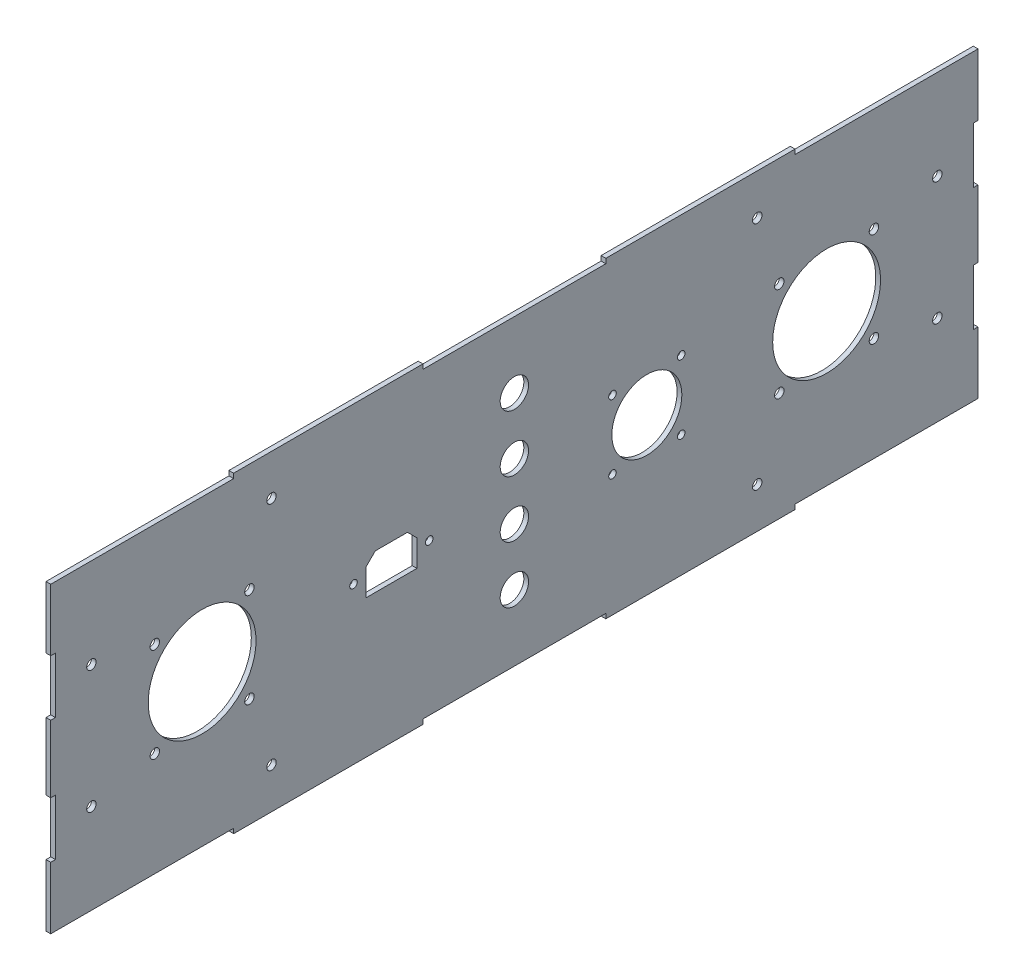
from build123d import *

# Parameters (mm, degrees)
BOSS_EXTRUDE1_DEPTH = 2.5
SKETCH2_R           = 2.5
SKETCH2_R_2         = 2
SKETCH2_R_3         = 18.5
SKETCH2_R_4         = 28.5
SKETCH2_R_5         = 7.5
SKETCH2_W           = 2.5
SKETCH2_H           = 29.5
CUT_EXTRUDE1_DEPTH  = 2.5


with BuildPart() as part:
    # Sketch1 → Boss-Extrude1 (new body)
    with BuildSketch(Plane(origin=(0, 0, 0), x_dir=(0, 0, -1), z_dir=(1, 0, 0))):
        Polygon((-245, -80), (-148.333333333, -80), (-148.333333333, -82.5), (-48.333333333, -82.5), (-48.333333333, -80), (48.333333333, -80), (48.333333333, -82.5), (148.333333333, -82.5), (148.333333333, -80), (245, -80), (245, 80), (148.333333333, 80), (148.333333333, 82.5), (48.333333333, 82.5), (48.333333333, 80), (-48.333333333, 80), (-48.333333333, 82.5), (-148.333333333, 82.5), (-148.333333333, 80), (-245, 80), align=None)
    extrude(amount=BOSS_EXTRUDE1_DEPTH)

    # Sketch2 → Cut-Extrude1 (cut)
    with BuildSketch(Plane(origin=(2.5, 0, 0), x_dir=(0, 0, -1), z_dir=(1, 0, 0))):
        with Locations((-128.333333333, 61)):
            Circle(SKETCH2_R)
        with Locations((128.333333333, 61)):
            Circle(SKETCH2_R)
        with Locations((128.333333333, -61)):
            Circle(SKETCH2_R)
        with Locations((-128.333333333, -61)):
            Circle(SKETCH2_R)
        with Locations((-223.5, 32.5)):
            Circle(SKETCH2_R)
        with Locations((-223.5, -32.5)):
            Circle(SKETCH2_R)
        with Locations((223.5, 32.5)):
            Circle(SKETCH2_R)
        with Locations((223.5, -32.5)):
            Circle(SKETCH2_R)
        with Locations((-85, 0)):
            Circle(SKETCH2_R_2)
        with Locations((-45, 0)):
            Circle(SKETCH2_R_2)
        with Locations((70, 0)):
            Circle(SKETCH2_R_3)
        with Locations((51.85, 18.15)):
            Circle(SKETCH2_R_2)
        with Locations((51.85, -18.15)):
            Circle(SKETCH2_R_2)
        with Locations((88.15, -18.15)):
            Circle(SKETCH2_R_2)
        with Locations((88.15, 18.15)):
            Circle(SKETCH2_R_2)
        with Locations((-190, -25)):
            Circle(SKETCH2_R)
        with Locations((-165, 0)):
            Circle(SKETCH2_R_4)
        with Locations((-140, -25)):
            Circle(SKETCH2_R)
        with Locations((-140, 25)):
            Circle(SKETCH2_R)
        with Locations((-190, 25)):
            Circle(SKETCH2_R)
        with Locations((165, 0)):
            Circle(SKETCH2_R_4)
        with Locations((190, -25)):
            Circle(SKETCH2_R)
        with Locations((140, -25)):
            Circle(SKETCH2_R)
        with Locations((140, 25)):
            Circle(SKETCH2_R)
        with Locations((190, 25)):
            Circle(SKETCH2_R)
        with Locations((0, 15)):
            Circle(SKETCH2_R_5)
        with Locations((0, -15)):
            Circle(SKETCH2_R_5)
        with Locations((0, 45)):
            Circle(SKETCH2_R_5)
        with Locations((0, -45)):
            Circle(SKETCH2_R_5)
        with Locations((-243.75, 32.5)):
            Rectangle(SKETCH2_W, SKETCH2_H)
        with Locations((-243.75, -32.5)):
            Rectangle(SKETCH2_W, SKETCH2_H)
        with Locations((243.75, -32.5)):
            Rectangle(SKETCH2_W, SKETCH2_H)
        with Locations((243.75, 32.5)):
            Rectangle(SKETCH2_W, SKETCH2_H)
        Polygon((-73.5, 9.5), (-78.5, 4.5), (-78.5, -9.5), (-51.5, -9.5), (-51.5, 4.5), (-56.5, 9.5), align=None)
    extrude(amount=-CUT_EXTRUDE1_DEPTH, mode=Mode.SUBTRACT)


solid = part.part
